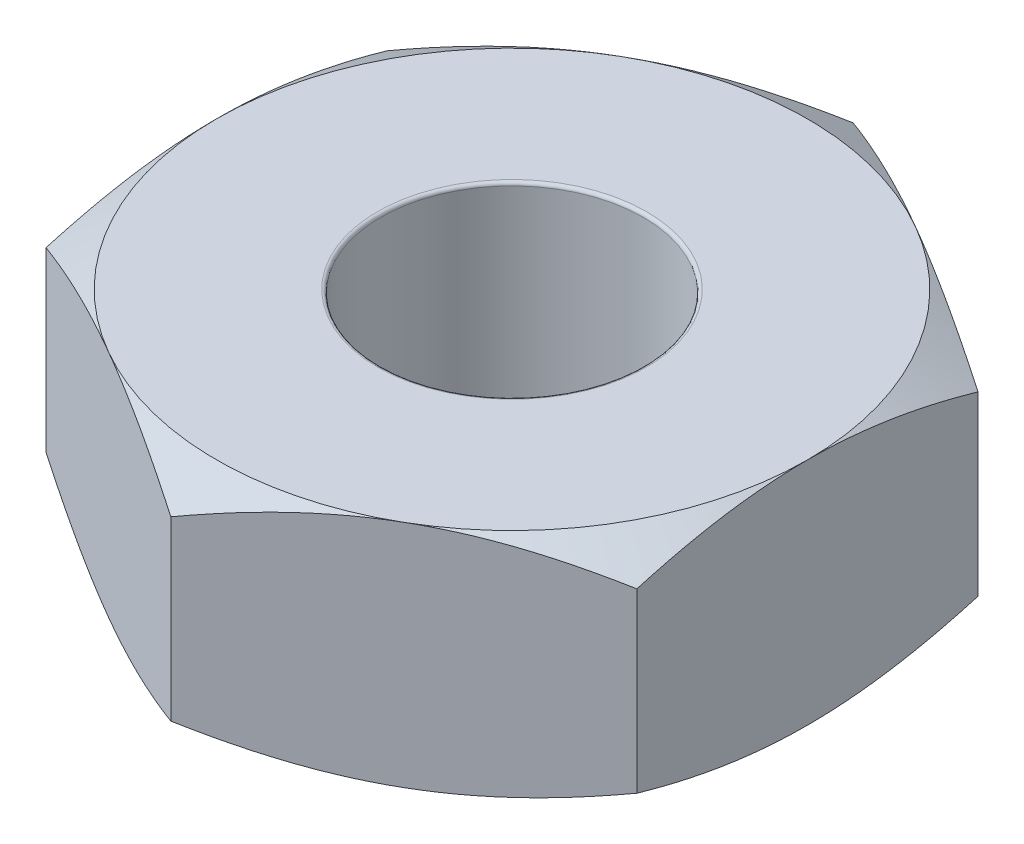
from build123d import *

# Parameters (mm, degrees)
SKETCH1_R           = 1
BOSS_EXTRUDE1_DEPTH = 1.75
SKETCH2_OUTSIDE_W   = 13.98
SKETCH2_OUTSIDE_H   = 14.676
SKETCH2_OUTSIDE_R   = 2.25
CUT_EXTRUDE1_DEPTH  = 1.75
CUT_EXTRUDE1_TAPER  = 60
SKETCH3_OUTSIDE_W   = 13.98
SKETCH3_OUTSIDE_H   = 14.676
SKETCH3_OUTSIDE_R   = 2.25
CUT_EXTRUDE3_DEPTH  = 1.75
CUT_EXTRUDE3_TAPER  = 60
FILLET1_R           = 0.025


with BuildPart() as part:
    # Sketch1 → Boss-Extrude1 (new body)
    with BuildSketch(Plane(origin=(0, 0, 0), x_dir=(1, 0, 0), z_dir=(0, 1, 0))):
        Polygon((2.25, -1.299038106), (2.25, 1.299038106), (0, 2.598076211), (-2.25, 1.299038106), (-2.25, -1.299038106), (0, -2.598076211), align=None)
        Circle(SKETCH1_R, mode=Mode.SUBTRACT)
    extrude(amount=BOSS_EXTRUDE1_DEPTH)

    # Sketch2 outside → Cut-Extrude1 (cut)
    with BuildSketch(Plane(origin=(0, 1.75, 0), x_dir=(1, 0, 0), z_dir=(0, 1, 0))):
        Rectangle(SKETCH2_OUTSIDE_W, SKETCH2_OUTSIDE_H)
        Circle(SKETCH2_OUTSIDE_R, mode=Mode.SUBTRACT)
    extrude(amount=-CUT_EXTRUDE1_DEPTH, taper=CUT_EXTRUDE1_TAPER, mode=Mode.SUBTRACT)

    # Sketch3 outside → Cut-Extrude3 (cut)
    with BuildSketch(Plane.XZ):
        Rectangle(SKETCH3_OUTSIDE_W, SKETCH3_OUTSIDE_H)
        Circle(SKETCH3_OUTSIDE_R, mode=Mode.SUBTRACT)
    extrude(amount=-CUT_EXTRUDE3_DEPTH, taper=CUT_EXTRUDE3_TAPER, mode=Mode.SUBTRACT)

    # Fillet1
    fillet1_edges = [part.edges().sort_by_distance(p)[0] for p in [
        (-1, 0, 0),
        (-1, 1.75, 0),
    ]]
    fillet(fillet1_edges, radius=FILLET1_R)


solid = part.part
